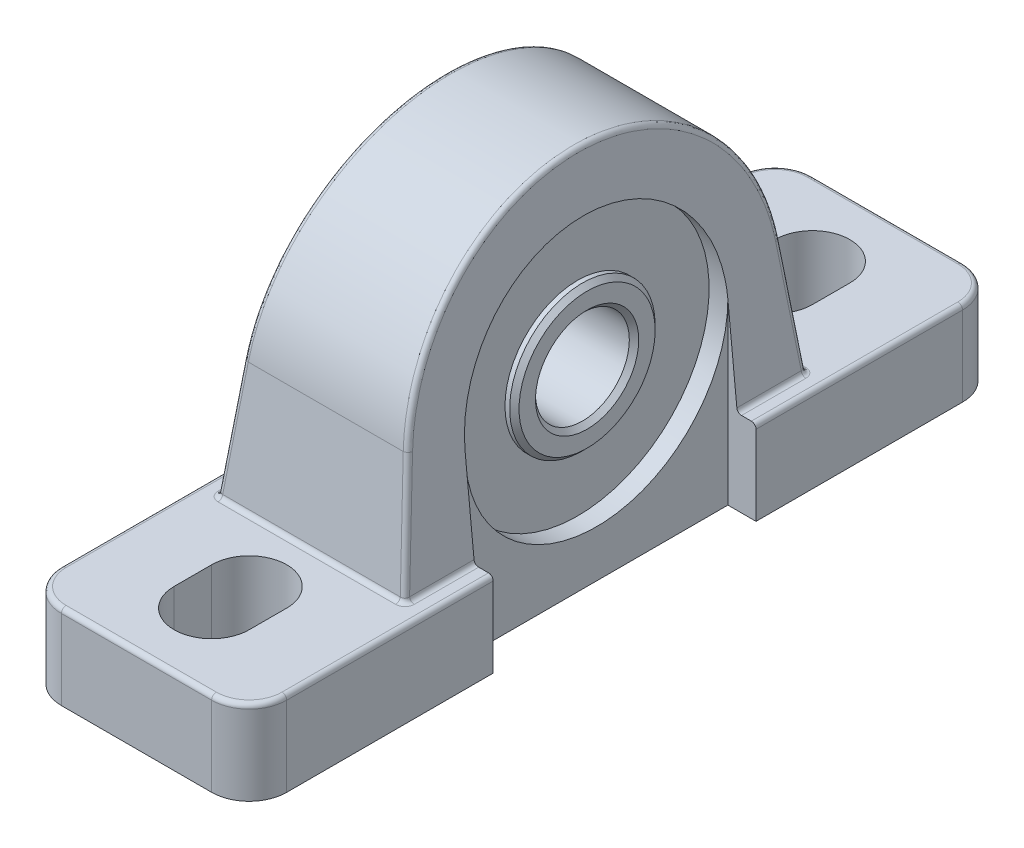
from build123d import *

# Parameters (mm, degrees)
SKETCH1_W           = 38.1
SKETCH1_H           = 127
BOSS_EXTRUDE1_DEPTH = 14.2875
BOSS_EXTRUDE2_DEPTH = 34
CUT_EXTRUDE1_DEPTH  = 25.4
SKETCH4_W           = 4.7625
SKETCH4_H           = 44.45
CUT_EXTRUDE2_DEPTH  = 62.9125
SKETCH6_R           = 22.225
CUT_EXTRUDE4_DEPTH  = 6.35
CUT_EXTRUDE5_DEPTH  = 15.2875
SKETCH8_R           = 12.303125
BOSS_EXTRUDE3_DEPTH = 31.0007
SKETCH9_R           = 7.9375
CUT_EXTRUDE6_DEPTH  = 38.3507
SKETCH10_R          = 22.225
SKETCH10_R_2        = 12.303125
CUT_EXTRUDE7_DEPTH  = 1.5875
FILLET1_R           = 6.35
FILLET3_R           = 0.79375
CHAMFER2_SIZE       = 0.79375
FILLET5_R           = 0.79375


with BuildPart() as part:
    # Sketch1 → Boss-Extrude1 (new body)
    with BuildSketch(Plane(origin=(0, 0, 0), x_dir=(1, 0, 0), z_dir=(0, 1, 0))):
        Rectangle(SKETCH1_W, SKETCH1_H)
    extrude(amount=BOSS_EXTRUDE1_DEPTH)

    # Sketch2 → Boss-Extrude2 (add, symmetric)
    with BuildSketch(Plane.XY):
        Polygon((-15.875, 14.2875), (-11.1125, 61.9125), (11.1125, 61.9125), (15.875, 14.2875), align=None)
    extrude(amount=BOSS_EXTRUDE2_DEPTH, both=True)

    # Sketch3 → Cut-Extrude1 (cut, symmetric)
    with BuildSketch(Plane(origin=(0, 0, 0), x_dir=(0, 0, -1), z_dir=(1, 0, 0))):
        with BuildLine():
            Line((-34, 14.2875), (-31.501184031, 34.129602806))
            ThreePointArc((-31.501184031, 34.129602806), (0, 61.9125), (31.501184031, 34.129602806))
            Line((31.501184031, 34.129602806), (34, 14.2875))
            Line((34, 14.2875), (34, 65.0875))
            Line((34, 65.0875), (-34, 65.0875))
            Line((-34, 65.0875), (-34, 14.2875))
        make_face()
    extrude(amount=CUT_EXTRUDE1_DEPTH, both=True, mode=Mode.SUBTRACT)

    # Sketch4 → Cut-Extrude2 (cut, through all)
    with BuildSketch(Plane(origin=(0, 0, 0), x_dir=(1, 0, 0), z_dir=(0, 1, 0))):
        with Locations((-16.66875, 0)):
            Rectangle(SKETCH4_W, SKETCH4_H)
    cut_extrude2 = extrude(amount=CUT_EXTRUDE2_DEPTH, mode=Mode.SUBTRACT)

    # Sketch6 → Cut-Extrude4 (cut)
    with BuildSketch(Plane.ZY.offset(19.05)):
        with Locations((0, 30.1625)):
            Circle(SKETCH6_R)
    cut_extrude4 = extrude(amount=-CUT_EXTRUDE4_DEPTH, mode=Mode.SUBTRACT)

    # Sketch7 → Cut-Extrude5 (cut, through all)
    with BuildSketch(Plane(origin=(0, 14.2875, 0), x_dir=(1, 0, 0), z_dir=(0, 1, 0))):
        with BuildLine():
            Line((6.35, -44.45), (6.35, -50.8))
            ThreePointArc((6.35, -50.8), (0, -57.15), (-6.35, -50.8))
            Line((-6.35, -50.8), (-6.35, -44.45))
            ThreePointArc((-6.35, -44.45), (0, -38.1), (6.35, -44.45))
        make_face()
        with BuildLine():
            Line((6.35, 44.45), (6.35, 50.8))
            ThreePointArc((6.35, 50.8), (0, 57.15), (-6.35, 50.8))
            Line((-6.35, 50.8), (-6.35, 44.45))
            ThreePointArc((-6.35, 44.45), (0, 38.1), (6.35, 44.45))
        make_face()
    extrude(amount=-CUT_EXTRUDE5_DEPTH, mode=Mode.SUBTRACT)

    # Sketch8 → Boss-Extrude3 (add)
    with BuildSketch(Plane.ZY.offset(-12.7)):
        with Locations((0, 30.1625)):
            Circle(SKETCH8_R)
    extrude(amount=BOSS_EXTRUDE3_DEPTH)

    # Sketch9 → Cut-Extrude6 (cut, through all)
    with BuildSketch(Plane.ZY.offset(18.3007)):
        with Locations((0, 30.1625)):
            Circle(SKETCH9_R)
    extrude(amount=-CUT_EXTRUDE6_DEPTH, mode=Mode.SUBTRACT)

    # Sketch10 → Cut-Extrude7 (cut)
    with BuildSketch(Plane.ZY.offset(12.7)):
        with Locations((0, 30.1625)):
            Circle(SKETCH10_R)
        with Locations((0, 30.1625)):
            Circle(SKETCH10_R_2, mode=Mode.SUBTRACT)
    cut_extrude7 = extrude(amount=-CUT_EXTRUDE7_DEPTH, mode=Mode.SUBTRACT)

    # Mirror2: Cut-Extrude2, Cut-Extrude4, Cut-Extrude7 across plane
    add(cut_extrude2.mirror(Plane(origin=(0, 0, 0), x_dir=(0, 0, 1), z_dir=(1, 0, 0))), mode=Mode.SUBTRACT)
    add(cut_extrude4.mirror(Plane(origin=(0, 0, 0), x_dir=(0, 0, 1), z_dir=(1, 0, 0))), mode=Mode.SUBTRACT)
    add(cut_extrude7.mirror(Plane(origin=(0, 0, 0), x_dir=(0, 0, 1), z_dir=(1, 0, 0))), mode=Mode.SUBTRACT)

    # Fillet1
    fillet1_edges = [part.edges().sort_by_distance(p)[0] for p in [
        (19.05, 7.14375, 63.5),
        (-19.05, 7.14375, 63.5),
        (-19.05, 7.14375, -63.5),
        (19.05, 7.14375, -63.5),
    ]]
    fillet(fillet1_edges, radius=FILLET1_R)

    # Fillet3
    fillet3_edges = [part.edges().sort_by_distance(p)[0] for p in [
        (19.05, 14.2875, -39.6875),
        (0, 14.2875, -63.5),
        (-19.05, 14.2875, -39.6875),
        (-17.190128061, 14.2875, -61.640128061),
        (17.190128061, 14.2875, -61.640128061),
        (19.05, 14.2875, 39.6875),
        (0, 14.2875, 63.5),
        (-17.190128061, 14.2875, 61.640128061),
        (17.190128061, 14.2875, 61.640128061),
        (-19.05, 14.2875, 39.6875),
    ]]
    fillet(fillet3_edges, radius=FILLET3_R)

    # Chamfer2
    chamfer2_edges = [part.edges().sort_by_distance(p)[0] for p in [
        (-18.3007, 30.1625, -12.303125),
        (-18.3007, 30.1625, -7.9375),
        (12.7, 30.1625, -7.9375),
        (12.7, 30.1625, -12.303125),
    ]]
    chamfer(chamfer2_edges, length=CHAMFER2_SIZE)

    # Fillet5
    fillet5_edges = [part.edges().sort_by_distance(p)[0] for p in [
        (15.875, 14.2875, -28.1125),
        (0, 14.2875, -34),
        (-15.875, 14.2875, 28.1125),
        (15.875, 14.2875, 28.1125),
        (0, 14.2875, 34),
        (-11.908575206, 53.951747942, 21.026987001),
        (11.908575206, 53.951747942, -21.026987001),
        (14.88289486, 24.208551403, 32.750592015),
        (-14.88289486, 24.208551403, 32.750592015),
        (14.88289486, 24.208551403, -32.750592015),
        (-14.88289486, 24.208551403, -32.750592015),
        (-15.875, 14.2875, -28.1125),
    ]]
    fillet(fillet5_edges, radius=FILLET5_R)


solid = part.part
